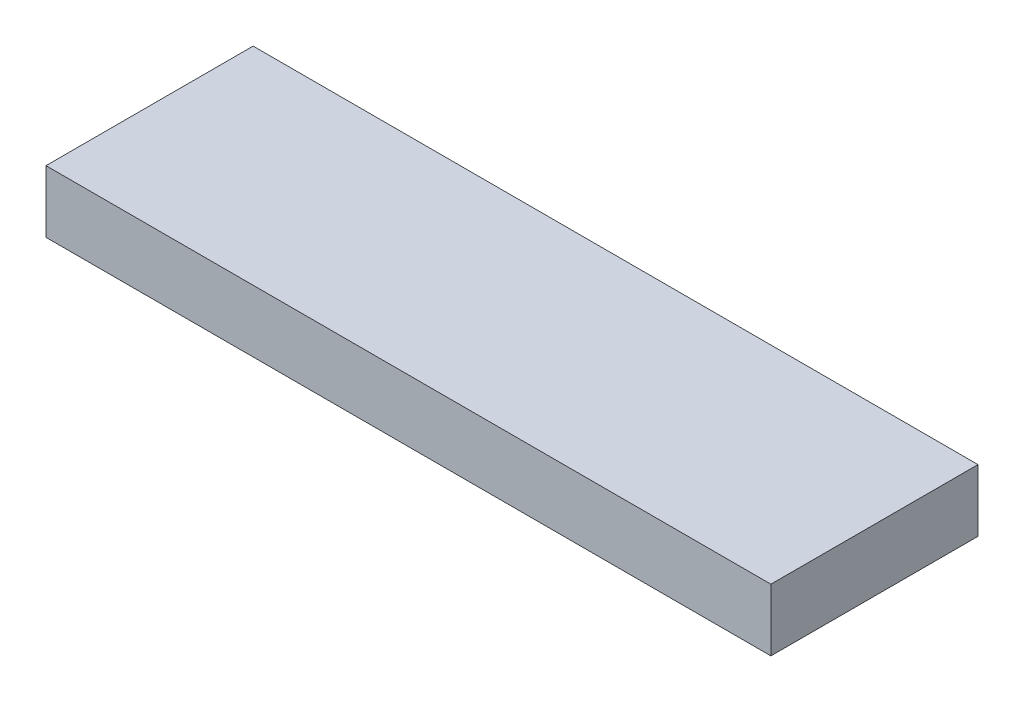
from build123d import *

# Parameters (mm, degrees)
SKETCH_1_W        = 70
SKETCH_1_H        = 20
EXTRUDE_292_DEPTH = 6


with BuildPart() as part:
    # Эскиз1 → Extrude 292 (new body)
    with BuildSketch(Plane(origin=(0, 0, 0), x_dir=(1, 0, 0), z_dir=(0, 1, 0))):
        with Locations((35, 10)):
            Rectangle(SKETCH_1_W, SKETCH_1_H)
    extrude(amount=EXTRUDE_292_DEPTH)


solid = part.part
